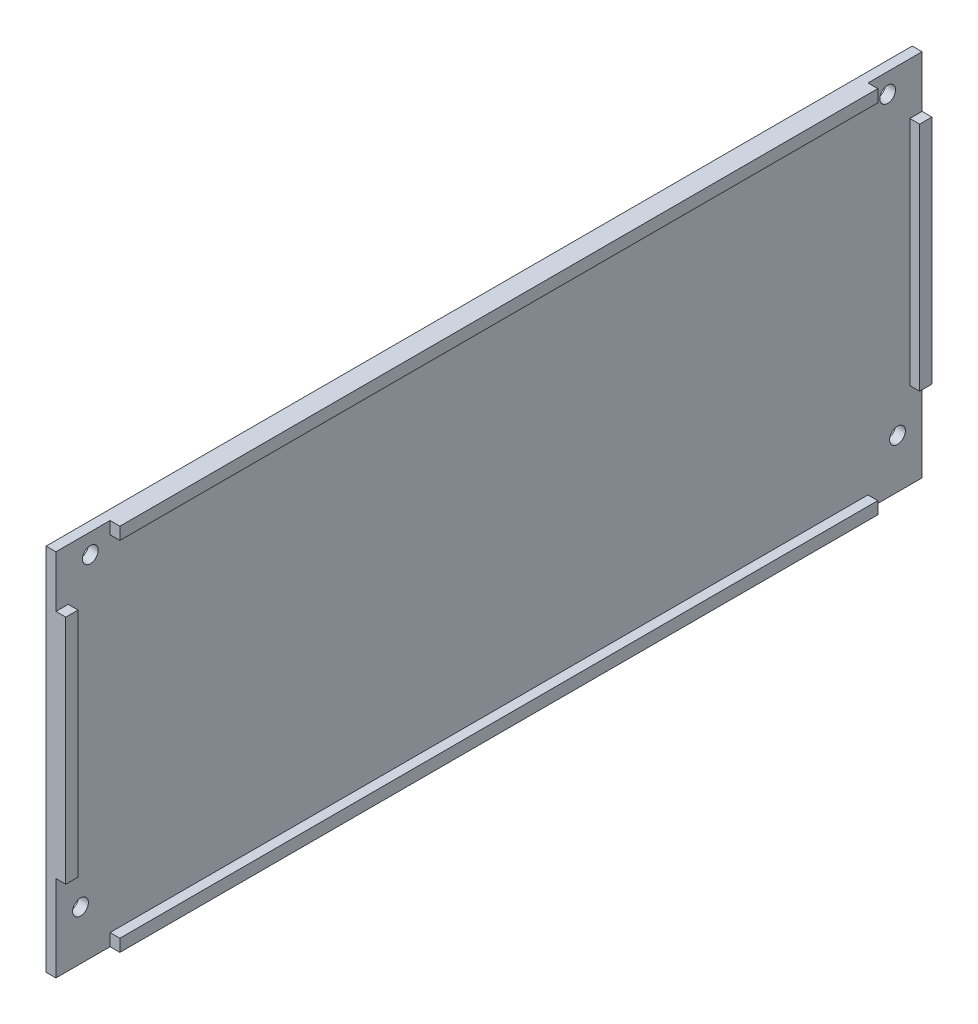
from build123d import *

# Parameters (mm, degrees)
SKETCH1_W           = 176
SKETCH1_H           = 75
SKETCH1_R           = 1.6
BOSS_EXTRUDE1_DEPTH = 2
SKETCH3_W           = 154
SKETCH3_H           = 2.5
BOSS_EXTRUDE2_DEPTH = 2
SKETCH4_W           = 2.5
SKETCH4_H           = 47
BOSS_EXTRUDE3_DEPTH = 2


with BuildPart() as part:
    # Sketch1 → Boss-Extrude1 (new body)
    with BuildSketch(Plane(origin=(0, 0, 0), x_dir=(0, 0, -1), z_dir=(1, 0, 0))):
        Rectangle(SKETCH1_W, SKETCH1_H)
        with Locations((-81, 33.5)):
            Circle(SKETCH1_R, mode=Mode.SUBTRACT)
        with Locations((81, 33.5)):
            Circle(SKETCH1_R, mode=Mode.SUBTRACT)
        with Locations((-83, -27.5)):
            Circle(SKETCH1_R, mode=Mode.SUBTRACT)
        with Locations((83, -27.5)):
            Circle(SKETCH1_R, mode=Mode.SUBTRACT)
    extrude(amount=BOSS_EXTRUDE1_DEPTH)

    # Sketch3 → Boss-Extrude2 (add)
    with BuildSketch(Plane(origin=(2, 0, 0), x_dir=(0, 0, -1), z_dir=(1, 0, 0))):
        with Locations((0, -36.25)):
            Rectangle(SKETCH3_W, SKETCH3_H)
        with Locations((0, 36.25)):
            Rectangle(SKETCH3_W, SKETCH3_H)
    extrude(amount=BOSS_EXTRUDE2_DEPTH)

    # Sketch4 → Boss-Extrude3 (add)
    with BuildSketch(Plane(origin=(2, 0, 0), x_dir=(0, 0, -1), z_dir=(1, 0, 0))):
        with Locations((-86.75, 3.5)):
            Rectangle(SKETCH4_W, SKETCH4_H)
        with Locations((86.75, 3.5)):
            Rectangle(SKETCH4_W, SKETCH4_H)
    extrude(amount=BOSS_EXTRUDE3_DEPTH)


solid = part.part
